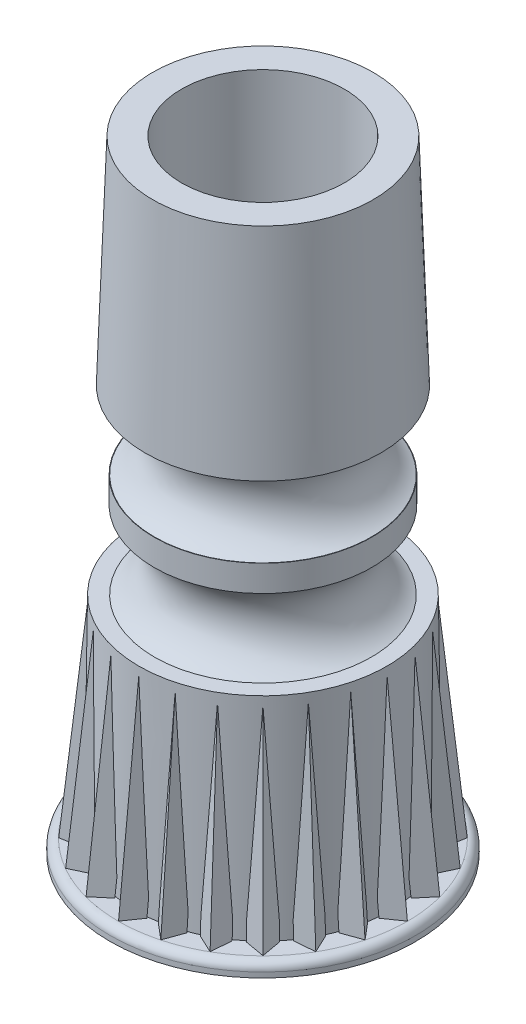
from build123d import *

# Parameters (mm, degrees)
SKETCH1_R           = 9.3345
BOSS_EXTRUDE1_DEPTH = 0.8128
BOSS_EXTRUDE1_TAPER = 1
SKETCH2_R           = 7.5692
SKETCH3_R           = 7.7343
CIRPATTERN3_COUNT   = 24
FILLET1_R           = 0.508
SKETCH20_R          = 6.731
BOSS_EXTRUDE2_DEPTH = 13.1572
BOSS_EXTRUDE2_DRAFT = -2
SKETCH21_R          = 4.9657
CUT_EXTRUDE1_DEPTH  = 12.2174
SKETCH22_R          = 2.1971
CUT_EXTRUDE2_DEPTH  = 38.8968


with BuildPart() as part:
    # Sketch1 → Boss-Extrude1 (new body)
    with BuildSketch(Plane(origin=(0, 0, 0), x_dir=(1, 0, 0), z_dir=(0, 1, 0))):
        Circle(SKETCH1_R)
    extrude(amount=BOSS_EXTRUDE1_DEPTH, taper=BOSS_EXTRUDE1_TAPER)

    # Sketch2 → Loft1 section 0
    with BuildSketch(Plane(origin=(0, 13.6652, 0), x_dir=(1, 0, 0), z_dir=(0, 1, 0))):
        Circle(SKETCH2_R)
    # Sketch3 → Loft1 section 1
    with BuildSketch(Plane(origin=(0, 0.8128, 0), x_dir=(1, 0, 0), z_dir=(0, 1, 0))):
        Circle(SKETCH3_R)
    loft()

    # Sweep1: sweep along a path in Sketch4
    with BuildLine(Plane(origin=(0, 0, 0), x_dir=(0, 0, -1), z_dir=(1, 0, 0))) as sweep1_path:
        Line((-8.812312523, 0.8128), (-7.575725692, 13.1572))
    # Sketch14 → Sweep1 (sweep)
    with BuildSketch(Plane(origin=(0, 0.8128, 8.812312523), x_dir=(1, 0, 0), z_dir=(0, 0.995020042, -0.09967505))):
        Polygon((0, 0), (-0.711410859, 1.016), (0.711410859, 1.016), align=None)
    sweep1 = sweep(path=sweep1_path.line)

    # CirPattern3: Sweep1 ×24 about axis
    cirpattern3_axis = Axis((0, 0, 0), (0, 1, 0))
    for i in range(1, CIRPATTERN3_COUNT):
        add(sweep1.rotate(cirpattern3_axis, i * 360 / CIRPATTERN3_COUNT))

    # Sketch7 → Revolve1 (revolve)
    with BuildSketch(Plane(origin=(0, 0, 0), x_dir=(0, 0, -1), z_dir=(1, 0, 0))):
        with BuildLine():
            Line((6.6421, 18.415), (6.6167, 18.415))
            ThreePointArc((6.6167, 18.415), (5.0927, 16.0401), (6.6167, 13.6652))
            Line((6.6167, 13.6652), (0, 13.6652))
            Line((0, 13.6652), (0, 26.2128))
            Line((0, 26.2128), (6.6167, 26.2128))
            Line((6.6167, 26.2128), (6.6167, 24.765))
            ThreePointArc((6.6167, 24.765), (5.0927, 22.3901), (6.6167, 20.0152))
            Line((6.6167, 20.0152), (6.6421, 20.0152))
            Line((6.6421, 20.0152), (6.6421, 18.415))
        make_face()
    revolve(axis=Axis((0, 13.6652, 0), (0, 1, 0)))

    # Sketch19 → Cut-Revolve1 (revolve, cut)
    with BuildSketch(Plane(origin=(0, 0, 0), x_dir=(0, 0, -1), z_dir=(1, 0, 0))):
        Polygon((3.2004, 0), (3.412325434, 12.1412), (5.567182638, 12.1412), (6.6294, 0), (6.6294, -2.54), (3.2004, -2.54), align=None)
    revolve(axis=Axis((0, 0, 0), (0, 1, 0)), mode=Mode.SUBTRACT)

    # Fillet1
    fillet1_edges = [part.edges().sort_by_distance(p)[0] for p in [
        (-9.320312523, 0.8128, 0),
    ]]
    fillet(fillet1_edges, radius=FILLET1_R)


with BuildPart() as boss_extrude2_tool:
    # Sketch20 → Boss-Extrude2 (with draft: the straight prism first)
    with BuildSketch(Plane(origin=(0, 37.8968, 0), x_dir=(-1, 0, 0), z_dir=(0, -1, 0))):
        Circle(SKETCH20_R)
    extrude(amount=BOSS_EXTRUDE2_DEPTH)
    # Boss-Extrude2: the draft: its side faces are tilted about the plane it starts from
    boss_extrude2_sides = [boss_extrude2_tool.faces().sort_by_distance(p)[0] for p in [
        (6.731, 31.3182, 0),
    ]]
    draft(boss_extrude2_sides, Plane(origin=(0, 37.8968, 0), x_dir=(-1, 0, 0), z_dir=(0, -1, 0)), BOSS_EXTRUDE2_DRAFT)


with BuildPart() as part_1:
    add(part.part)

    # Boss-Extrude2: add boss_extrude2_tool
    add(boss_extrude2_tool.part)

    # Sketch21 → Cut-Extrude1 (cut)
    with BuildSketch(Plane(origin=(0, 37.8968, 0), x_dir=(1, 0, 0), z_dir=(0, 1, 0))):
        with Locations(Location((0, 0, 0), (0, 0, 270))):  # turned: the seam where the file's is
            Circle(SKETCH21_R)
    extrude(amount=-CUT_EXTRUDE1_DEPTH, mode=Mode.SUBTRACT)

    # Sketch22 → Cut-Extrude2 (cut, through all)
    with BuildSketch(Plane.XZ):
        with Locations(Location((0, 0, 0), (0, 0, 270))):  # turned: the seam where the file's is
            Circle(SKETCH22_R)
    extrude(amount=-CUT_EXTRUDE2_DEPTH, mode=Mode.SUBTRACT)


solid = part_1.part
